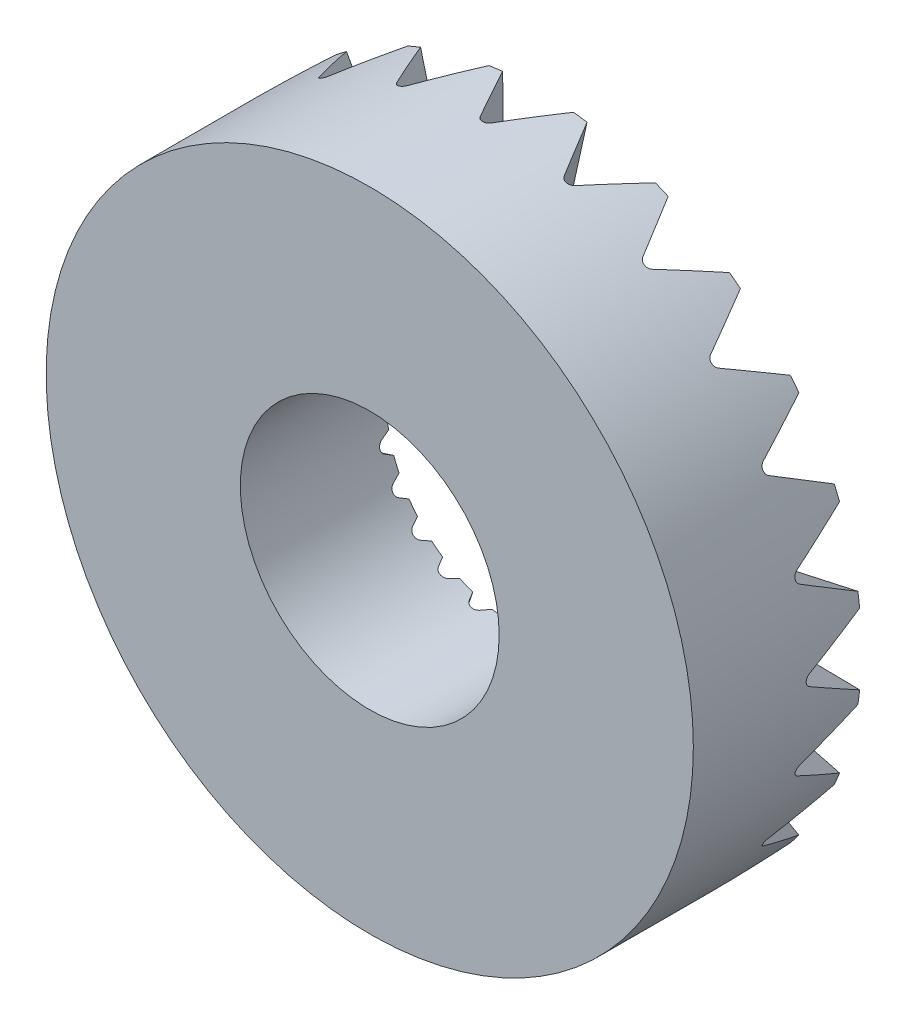
from build123d import *

# Parameters (mm, degrees)
SCHNITT_LINEAR_AUSTRAGEN1_DEPTH = 26.576407132
KREISMUSTER1_COUNT              = 24


with BuildPart() as part:
    # Skizze1 → Rotation1 (revolve)
    with BuildSketch(Plane(origin=(0, 0, 0), x_dir=(0, 0, -1), z_dir=(1, 0, 0)), mode=Mode.PRIVATE) as rotation1_sk:
        Polygon((0, 10), (0, 25), (13, 25), (11.285556945, 10), align=None)
    revolve(rotation1_sk.sketch.rotate(Axis((0, 0, 0), (0, 0, -1)), 90), axis=Axis((0, 0, 0), (0, 0, -1)))  # turned: the seam where the file's is

    # Skizze3 → Schnitt-Linear austragen1 (cut, through all)
    with BuildSketch(Plane(origin=(-0.73334518, 0, -0.08381857), x_dir=(0.113556878, 0, -0.993531497), z_dir=(0.993531497, 0, 0.113556878))):
        with BuildLine():
            Line((19.660254038, 5), (19.660254038, -5))
            Line((19.660254038, -5), (11.75, -0.433012702))
            ThreePointArc((11.75, -0.433012702), (11.5, 0), (11.75, 0.433012702))
            Line((11.75, 0.433012702), (19.660254038, 5))
        make_face()
    schnitt_linear_austragen1 = extrude(amount=SCHNITT_LINEAR_AUSTRAGEN1_DEPTH, mode=Mode.SUBTRACT)

    # Kreismuster1: Schnitt-Linear austragen1 ×24 about axis
    kreismuster1_axis = Axis((0, 0, 0), (0, 0, 1))
    for i in range(1, KREISMUSTER1_COUNT):
        add(schnitt_linear_austragen1.rotate(kreismuster1_axis, i * 360 / KREISMUSTER1_COUNT), mode=Mode.SUBTRACT)


solid = part.part
